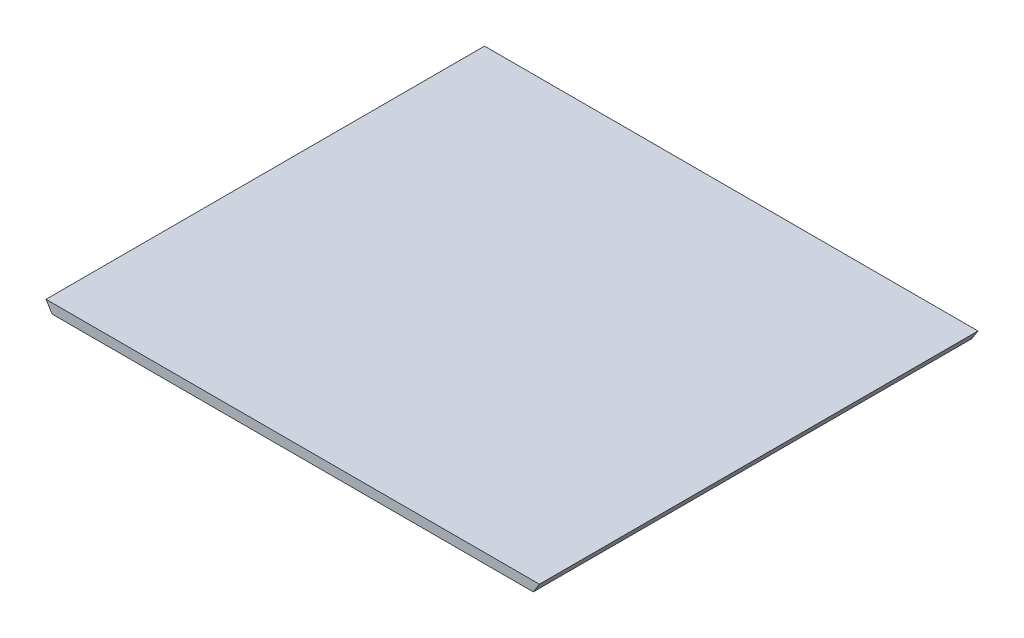
from build123d import *

# Parameters (mm, degrees)
AUFSATZ_LINEAR_AUSTRAGEN1_DEPTH = 450


with BuildPart() as part:
    # Skizze1 → Aufsatz-Linear austragen1 (new body)
    with BuildSketch(Plane.XY):
        Polygon((-253.156995608, 264.02367356), (-246.858259494, 254.02367356), (246.858259494, 254.02367356), (253.156995608, 264.02367356), align=None)
    extrude(amount=AUFSATZ_LINEAR_AUSTRAGEN1_DEPTH)


solid = part.part
